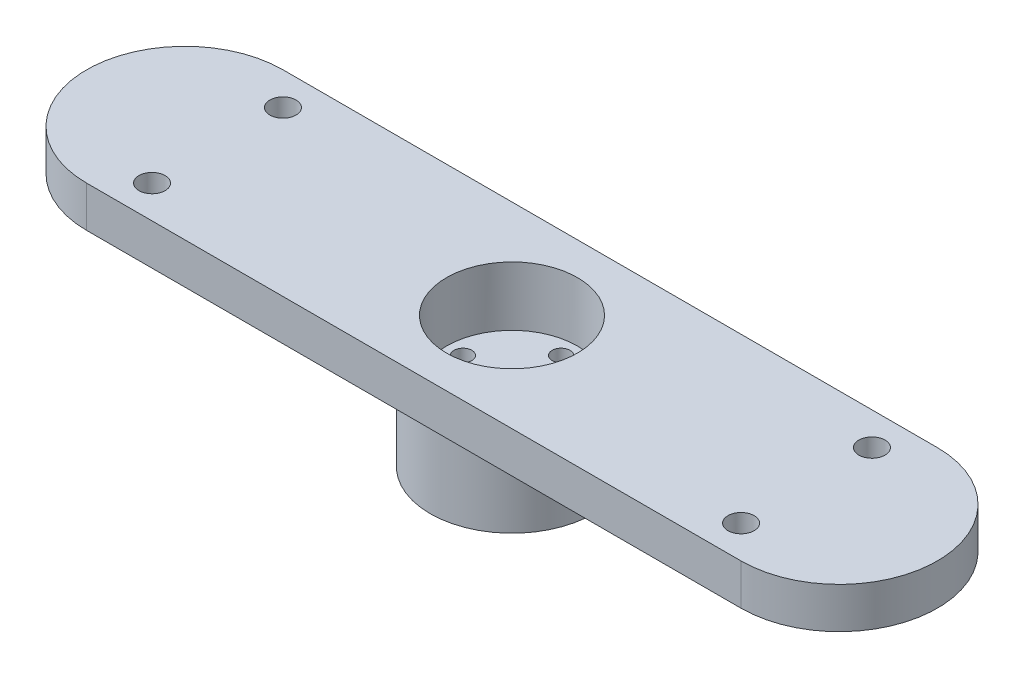
from build123d import *

# Parameters (mm, degrees)
SKETCH1_R           = 15.875
BOSS_EXTRUDE1_DEPTH = 25.4
CUT_EXTRUDE5_START  = -11.49604
SKETCH2_R           = 12.7
CUT_EXTRUDE5_DEPTH  = 11.49604
SKETCH3_R           = 1.7272
CUT_EXTRUDE6_DEPTH  = 26.4
CIRPATTERN3_COUNT   = 4
SKETCH6_R           = 15.875
BOSS_EXTRUDE2_DEPTH = 7.9502
SKETCH7_R           = 2.54
CUT_EXTRUDE7_DEPTH  = 26.4
CHAMFER1_SIZE       = 2.38


with BuildPart() as part:
    # Sketch1 → Boss-Extrude1 (new body)
    with BuildSketch(Plane(origin=(0, 0, 0), x_dir=(1, 0, 0), z_dir=(0, 1, 0))):
        Circle(SKETCH1_R)
    extrude(amount=BOSS_EXTRUDE1_DEPTH)

    # Sketch2 → Cut-Extrude5 (cut)
    with BuildSketch(Plane(origin=(0, 25.4, 0), x_dir=(1, 0, 0), z_dir=(0, 1, 0)).offset(CUT_EXTRUDE5_START)):
        Circle(SKETCH2_R)
    extrude(amount=CUT_EXTRUDE5_DEPTH, mode=Mode.SUBTRACT)

    # Sketch3 → Cut-Extrude6 (cut, through all)
    with BuildSketch(Plane.XZ):
        with Locations((0, 9.525)):
            Circle(SKETCH3_R)
    cut_extrude6 = extrude(amount=-CUT_EXTRUDE6_DEPTH, mode=Mode.SUBTRACT)

    # CirPattern3: Cut-Extrude6 ×4 about axis
    cirpattern3_axis = Axis((0, 0, 0), (0, 1, 0))
    for i in range(1, CIRPATTERN3_COUNT):
        add(cut_extrude6.rotate(cirpattern3_axis, i * 360 / CIRPATTERN3_COUNT), mode=Mode.SUBTRACT)

    # Sketch6 → Boss-Extrude2 (add)
    with BuildSketch(Plane(origin=(0, 25.4, 0), x_dir=(1, 0, 0), z_dir=(0, 1, 0))):
        with BuildLine():
            Line((-63.5, 19.05), (63.5, 19.05))
            ThreePointArc((63.5, 19.05), (82.55, 0), (63.5, -19.05))
            Line((63.5, -19.05), (-63.5, -19.05))
            ThreePointArc((-63.5, -19.05), (-82.55, 0), (-63.5, 19.05))
        make_face()
        Circle(SKETCH6_R, mode=Mode.SUBTRACT)
    extrude(amount=-BOSS_EXTRUDE2_DEPTH)

    # Sketch7 → Cut-Extrude7 (cut, through all)
    with BuildSketch(Plane(origin=(0, 25.4, 0), x_dir=(1, 0, 0), z_dir=(0, 1, 0))):
        with Locations((57.15, 12.7)):
            Circle(SKETCH7_R)
        with Locations((57.15, -12.7)):
            Circle(SKETCH7_R)
        with Locations((-57.15, -12.7)):
            Circle(SKETCH7_R)
        with Locations((-57.15, 12.7)):
            Circle(SKETCH7_R)
    extrude(amount=-CUT_EXTRUDE7_DEPTH, mode=Mode.SUBTRACT)

    # Chamfer1
    chamfer1_edges = [part.edges().sort_by_distance(p)[0] for p in [
        (-15.875, 17.4498, 0),
    ]]
    chamfer(chamfer1_edges, length=CHAMFER1_SIZE)


solid = part.part
